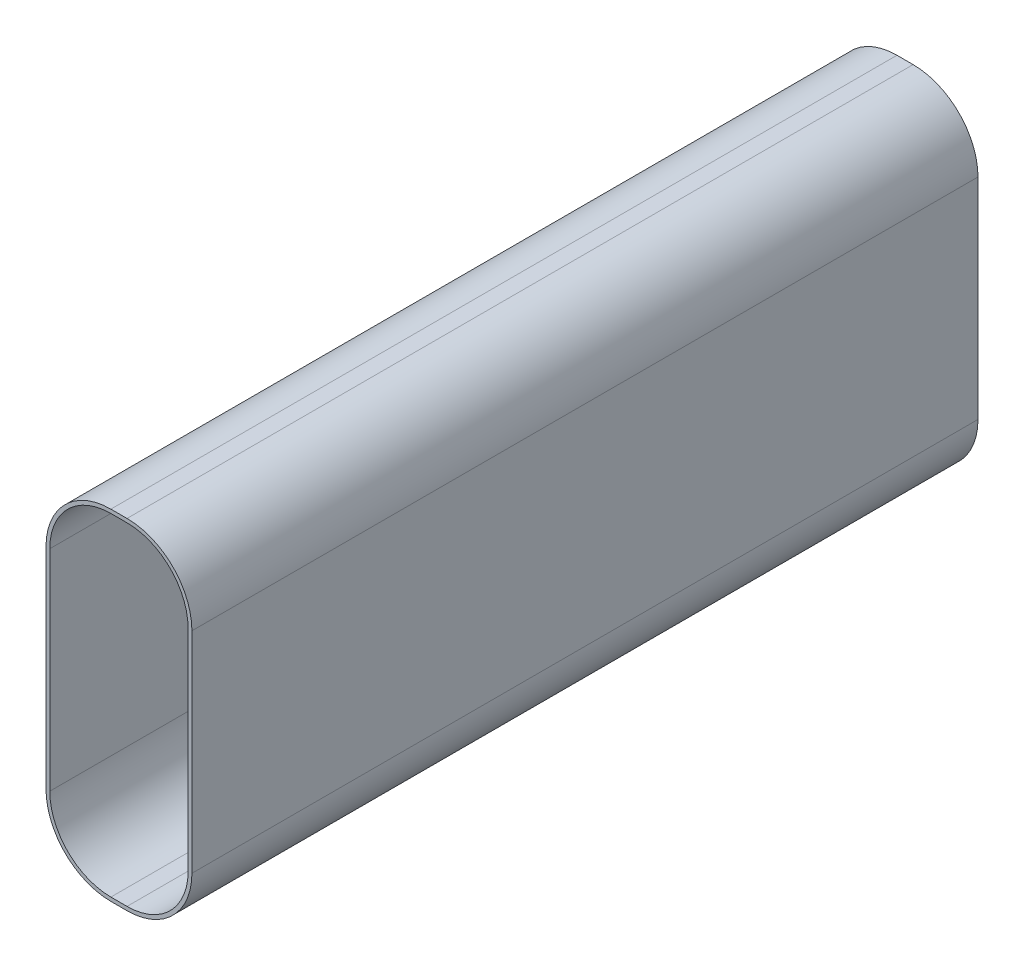
from build123d import *

# Parameters (mm, degrees)
EXTRUDE1_DEPTH = 37.084


with BuildPart() as part:
    # Sketch1 → Extrude1 (new body)
    with BuildSketch(Plane.XY):
        with BuildLine():
            Line((3.4417, 4.953), (3.4417, -4.953))
            ThreePointArc((3.4417, -4.953), (2.545241725, -7.117241725), (0.381, -8.0137))
            Line((0.381, -8.0137), (-0.381, -8.0137))
            ThreePointArc((-0.381, -8.0137), (-2.545241725, -7.117241725), (-3.4417, -4.953))
            Line((-3.4417, -4.953), (-3.4417, 4.953))
            ThreePointArc((-3.4417, 4.953), (-2.545241725, 7.117241725), (-0.381, 8.0137))
            Line((-0.381, 8.0137), (0.381, 8.0137))
            ThreePointArc((0.381, 8.0137), (2.545241725, 7.117241725), (3.4417, 4.953))
        make_face()
        with BuildLine():
            Line((3.2639, 4.953), (3.2639, -4.953))
            ThreePointArc((3.2639, -4.953), (2.419518139, -6.991518139), (0.381, -7.8359))
            Line((0.381, -7.8359), (-0.381, -7.8359))
            ThreePointArc((-0.381, -7.8359), (-2.419518139, -6.991518139), (-3.2639, -4.953))
            Line((-3.2639, -4.953), (-3.2639, 4.953))
            ThreePointArc((-3.2639, 4.953), (-2.419518139, 6.991518139), (-0.381, 7.8359))
            Line((-0.381, 7.8359), (0.381, 7.8359))
            ThreePointArc((0.381, 7.8359), (2.419518139, 6.991518139), (3.2639, 4.953))
        make_face(mode=Mode.SUBTRACT)
    extrude(amount=EXTRUDE1_DEPTH)


solid = part.part
